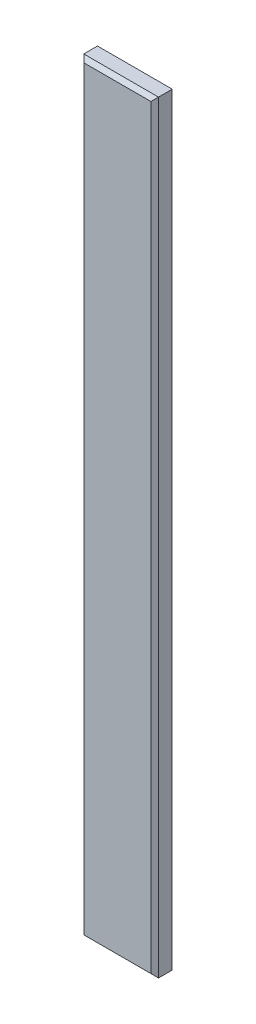
from build123d import *

# Parameters (mm, degrees)
SKETCH1_W           = 9.8
SKETCH1_H           = 2.8
BOSS_EXTRUDE1_DEPTH = 100
CHAMFER1_SIZE       = 0.5


with BuildPart() as part:
    # Sketch1 → Boss-Extrude1 (new body)
    with BuildSketch(Plane(origin=(0, 0, 0), x_dir=(1, 0, 0), z_dir=(0, 1, 0))):
        Rectangle(SKETCH1_W, SKETCH1_H)
    extrude(amount=BOSS_EXTRUDE1_DEPTH)

    # Chamfer1
    chamfer1_edges = [part.edges().sort_by_distance(p)[0] for p in [
        (0, 100, 1.4),
        (0, 0, 1.4),
        (0, 0, -1.4),
        (4.9, 50, 1.4),
        (-4.9, 50, 1.4),
        (-4.9, 50, -1.4),
        (4.9, 50, -1.4),
        (0, 100, -1.4),
    ]]
    chamfer(chamfer1_edges, length=CHAMFER1_SIZE)


solid = part.part
